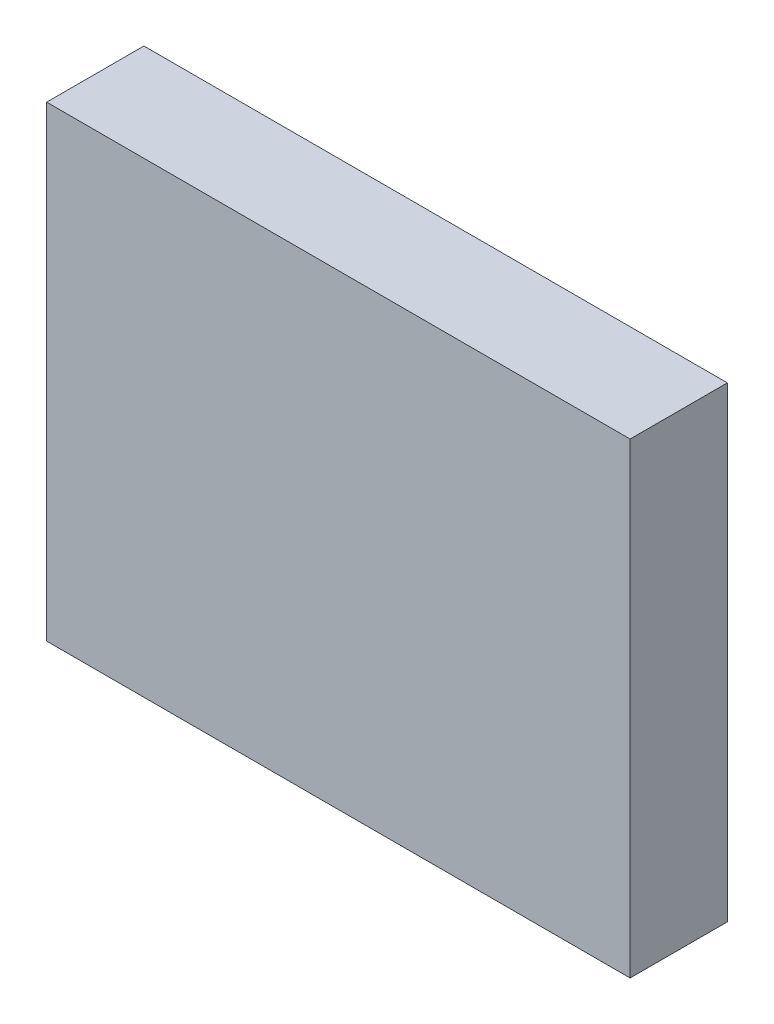
from build123d import *

# Parameters (mm, degrees)
ESQUISSE1_W        = 30
ESQUISSE1_H        = 24
BOSS_EXTRU_1_DEPTH = 5


with BuildPart() as part:
    # Esquisse1 → Boss.-Extru.1 (new body)
    with BuildSketch(Plane.XY):
        with Locations((5.839494196, 1.214864865)):
            Rectangle(ESQUISSE1_W, ESQUISSE1_H)
    extrude(amount=BOSS_EXTRU_1_DEPTH)


solid = part.part
